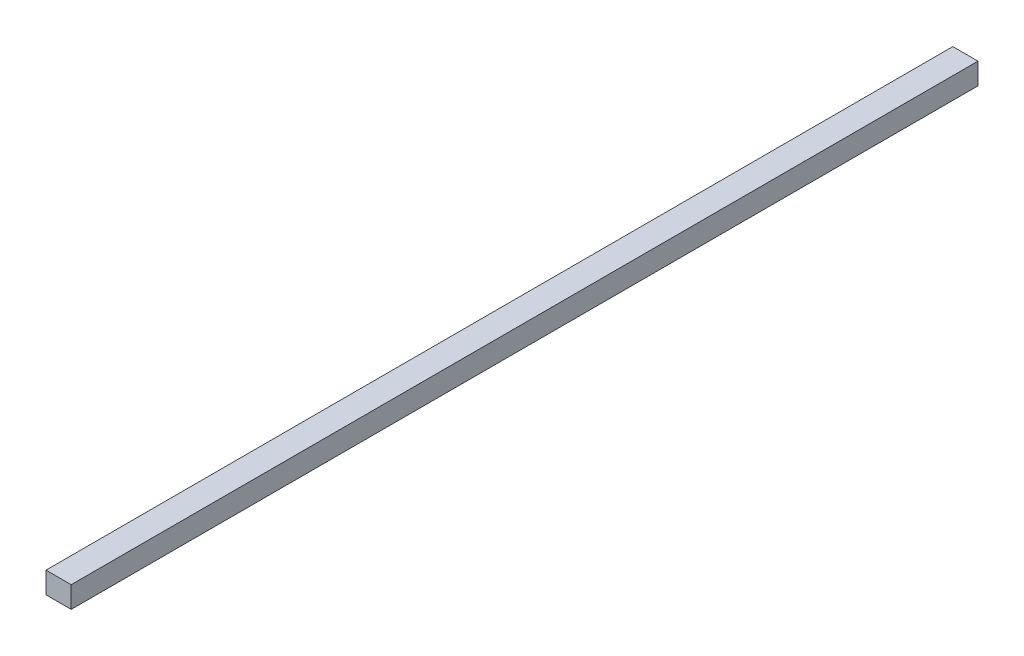
from build123d import *

# Parameters (mm, degrees)
SKETCH1_W           = 72
SKETCH1_H           = 1.7
BOSS_EXTRUDE1_DEPTH = 2


with BuildPart() as part:
    # Sketch1 → Boss-Extrude1 (new body)
    with BuildSketch(Plane(origin=(0, 0, 0), x_dir=(0, 0, -1), z_dir=(1, 0, 0))):
        with Locations((-26.527244469, 11.962620055)):
            Rectangle(SKETCH1_W, SKETCH1_H)
    extrude(amount=BOSS_EXTRUDE1_DEPTH)


solid = part.part
